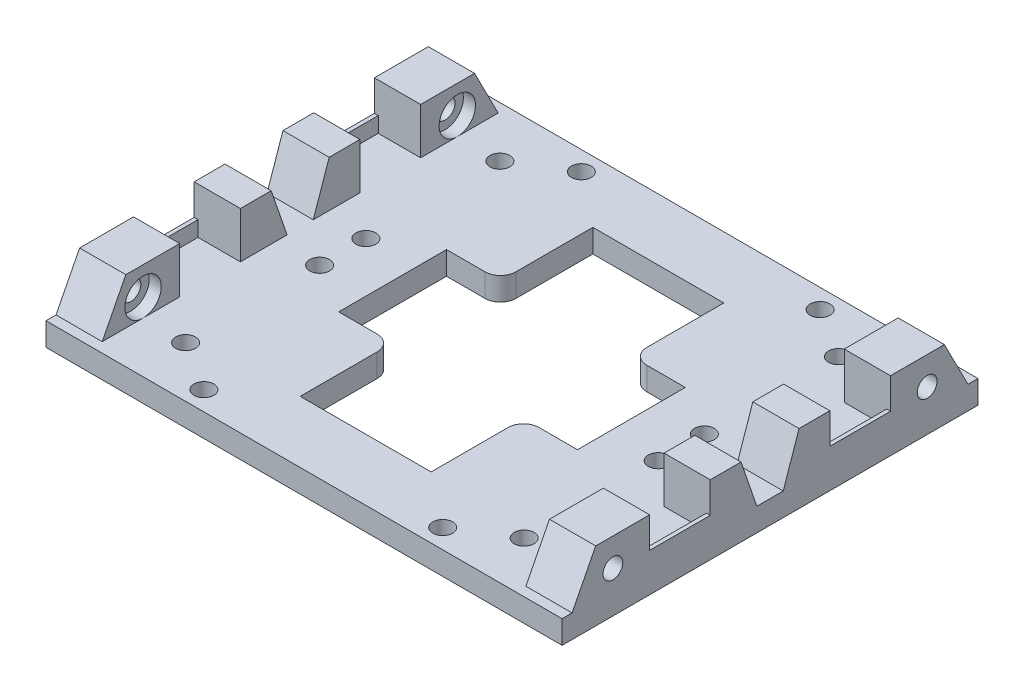
from build123d import *

# Parameters (mm, degrees)
SKETCH1_W                    = 85.09
SKETCH1_H                    = 68.58
BOSS_EXTRUDE1_DEPTH          = 5.08
F_30_0_1285_DIAMETER_HOLE1_D = 3.2639
SKETCH3_W                    = 31.877
SKETCH3_H                    = 68.58
SKETCH3_W_2                  = 53.213
CUT_EXTRUDE1_DEPTH           = 1.27
F_30_0_1285_DIAMETER_HOLE2_D = 3.2639
BOSS_EXTRUDE2_DEPTH          = 7.62
SKETCH10_W                   = 10
SKETCH10_H                   = 2.54
BOSS_EXTRUDE3_DEPTH          = 0.635
BOSS_EXTRUDE4_DEPTH          = 7.62
SKETCH12_W                   = 10
SKETCH12_H                   = 2.54
BOSS_EXTRUDE5_DEPTH          = 0.635
SKETCH13_W                   = 21.59
SKETCH13_H                   = 15.24
SKETCH13_W_2                 = 8.89
SKETCH13_H_2                 = 17.78
CUT_EXTRUDE3_DEPTH           = 4.81
FILLET1_R                    = 2.54
CUT_EXTRUDE4_START           = -7.62
SKETCH14_R                   = 1.63195
CUT_EXTRUDE4_DEPTH           = 8.62
CUT_EXTRUDE4_DEPTH_BACK      = 86.09
CUT_EXTRUDE5_START           = -7.62
SKETCH14_3_R                 = 3
SKETCH14_3_R_2               = 1.63195
CUT_EXTRUDE5_DEPTH           = 2
CUT_EXTRUDE6_START           = -77.47
SKETCH14_4_R                 = 3
SKETCH14_4_R_2               = 1.63195
CUT_EXTRUDE6_DEPTH           = 2


with BuildPart() as part:
    # Sketch1 → Boss-Extrude1 (new body)
    with BuildSketch(Plane(origin=(0, 0, 0), x_dir=(1, 0, 0), z_dir=(0, 1, 0))):
        with Locations((42.545, 34.29)):
            Rectangle(SKETCH1_W, SKETCH1_H)
    extrude(amount=BOSS_EXTRUDE1_DEPTH)

    # 30 _0.1285_ Diameter Hole1 (through all)
    with Locations(Plane(origin=(62.23, 5.08, -65.405), x_dir=(0, 0, 1), z_dir=(0, 1, 0))):
        with Locations((0, 0), (0, -39.37), (62.23, -39.37), (62.23, 0)):
            Hole(F_30_0_1285_DIAMETER_HOLE1_D / 2)

    # Sketch3 → Cut-Extrude1 (cut)
    with BuildSketch(Plane(origin=(0, 5.08, 0), x_dir=(1, 0, 0), z_dir=(0, 1, 0))):
        with Locations((69.1515, 34.29)):
            Rectangle(SKETCH3_W, SKETCH3_H)
        with Locations((26.6065, 34.29)):
            Rectangle(SKETCH3_W_2, SKETCH3_H)
    extrude(amount=-CUT_EXTRUDE1_DEPTH, mode=Mode.SUBTRACT)

    # 30 _0.1285_ Diameter Hole2 (through all)
    with Locations(Plane(origin=(70.455, 3.81, -38.1), x_dir=(0, 0, 1), z_dir=(0, 1, 0))):
        with Locations((0, 0), (-22.098, 0), (7.62, 0), (29.718, 0), (29.718, -55.82), (7.62, -55.82), (0, -55.82), (-22.098, -55.82)):
            Hole(F_30_0_1285_DIAMETER_HOLE2_D / 2)

    # Sketch9 → Boss-Extrude2 (add)
    with BuildSketch(Plane.ZY):
        Polygon((-14.431, 3.81), (-1.651, 3.81), (-5.541, 11.43), (-14.431, 11.43), align=None)
        Polygon((-24.431, 3.81), (-24.431, 11.43), (-29.511, 11.43), (-32.131, 3.81), align=None)
        Polygon((-44.149, 3.81), (-44.149, 11.43), (-39.069, 11.43), (-36.449, 3.81), align=None)
        Polygon((-54.149, 3.81), (-54.149, 11.43), (-63.039, 11.43), (-66.929, 3.81), align=None)
    extrude(amount=-BOSS_EXTRUDE2_DEPTH)

    # Sketch10 → Boss-Extrude3 (add)
    with BuildSketch(Plane.ZY):
        with Locations((-49.149, 5.08)):
            Rectangle(SKETCH10_W, SKETCH10_H)
        with Locations((-19.431, 5.08)):
            Rectangle(SKETCH10_W, SKETCH10_H)
    extrude(amount=-BOSS_EXTRUDE3_DEPTH)

    # Sketch11 → Boss-Extrude4 (add)
    with BuildSketch(Plane(origin=(85.09, 0, 0), x_dir=(0, 0, -1), z_dir=(1, 0, 0))):
        Polygon((24.431, 3.81), (24.431, 11.43), (29.511, 11.43), (32.11195, 3.81), align=None)
        Polygon((44.149, 3.81), (44.149, 11.43), (39.069, 11.43), (36.46805, 3.81), align=None)
        Polygon((14.431, 11.43), (14.431, 3.81), (1.651, 3.81), (5.541, 11.43), align=None)
        Polygon((63.039, 11.43), (66.929, 3.81), (54.149, 3.81), (54.149, 11.43), align=None)
    extrude(amount=-BOSS_EXTRUDE4_DEPTH)

    # Sketch12 → Boss-Extrude5 (add)
    with BuildSketch(Plane(origin=(85.09, 0, 0), x_dir=(0, 0, -1), z_dir=(1, 0, 0))):
        with Locations((19.431, 5.08)):
            Rectangle(SKETCH12_W, SKETCH12_H)
        with Locations((49.149, 5.08)):
            Rectangle(SKETCH12_W, SKETCH12_H)
    extrude(amount=-BOSS_EXTRUDE5_DEPTH)

    # Sketch13 → Cut-Extrude3 (cut, through all)
    with BuildSketch(Plane(origin=(0, 3.81, 0), x_dir=(1, 0, 0), z_dir=(0, 1, 0))):
        with Locations((42.545, 50.8)):
            Rectangle(SKETCH13_W, SKETCH13_H)
        with Locations((27.305, 34.29)):
            Rectangle(SKETCH13_W_2, SKETCH13_H_2)
        with Locations((42.545, 34.29)):
            Rectangle(SKETCH13_W, SKETCH13_H_2)
        with Locations((57.785, 34.29)):
            Rectangle(SKETCH13_W_2, SKETCH13_H_2)
        with Locations((42.545, 17.78)):
            Rectangle(SKETCH13_W, SKETCH13_H)
    extrude(amount=-CUT_EXTRUDE3_DEPTH, mode=Mode.SUBTRACT)

    # Fillet1
    fillet1_edges = [part.edges().sort_by_distance(p)[0] for p in [
        (31.75, 1.905, -43.18),
        (53.34, 1.905, -43.18),
        (53.34, 1.905, -25.4),
        (31.75, 1.905, -25.4),
    ]]
    fillet(fillet1_edges, radius=FILLET1_R)

    # Sketch14 → Cut-Extrude4 (cut, two sides)
    with BuildSketch(Plane(origin=(85.09, 0, 0), x_dir=(0, 0, -1), z_dir=(1, 0, 0)).offset(CUT_EXTRUDE4_START)) as cut_extrude4_sk:
        with Locations((8.382, 6.81)):
            Circle(SKETCH14_R)
        with Locations((60.198, 6.81)):
            Circle(SKETCH14_R)
    extrude(amount=CUT_EXTRUDE4_DEPTH, mode=Mode.SUBTRACT)
    extrude(cut_extrude4_sk.sketch, amount=-CUT_EXTRUDE4_DEPTH_BACK, mode=Mode.SUBTRACT)

    # Sketch14_3 → Cut-Extrude5 (cut)
    with BuildSketch(Plane(origin=(85.09, 0, 0), x_dir=(0, 0, -1), z_dir=(1, 0, 0)).offset(CUT_EXTRUDE5_START)):
        with Locations((8.382, 6.81)):
            Circle(SKETCH14_3_R)
        with Locations((8.382, 6.81)):
            Circle(SKETCH14_3_R_2, mode=Mode.SUBTRACT)
        with Locations((60.198, 6.81)):
            Circle(SKETCH14_3_R)
        with Locations((60.198, 6.81)):
            Circle(SKETCH14_3_R_2, mode=Mode.SUBTRACT)
    extrude(amount=CUT_EXTRUDE5_DEPTH, mode=Mode.SUBTRACT)

    # Sketch14_4 → Cut-Extrude6 (cut)
    with BuildSketch(Plane(origin=(85.09, 0, 0), x_dir=(0, 0, -1), z_dir=(1, 0, 0)).offset(CUT_EXTRUDE6_START)):
        with Locations((8.382, 6.81)):
            Circle(SKETCH14_4_R)
        with Locations((8.382, 6.81)):
            Circle(SKETCH14_4_R_2, mode=Mode.SUBTRACT)
        with Locations((60.198, 6.81)):
            Circle(SKETCH14_4_R)
        with Locations((60.198, 6.81)):
            Circle(SKETCH14_4_R_2, mode=Mode.SUBTRACT)
    extrude(amount=-CUT_EXTRUDE6_DEPTH, mode=Mode.SUBTRACT)


solid = part.part
